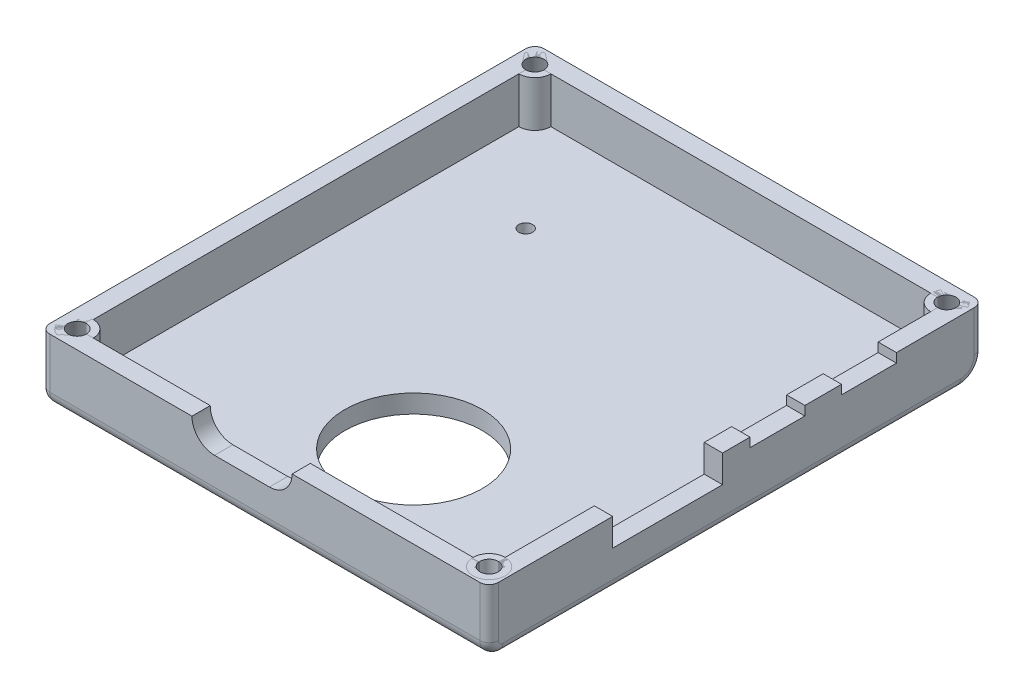
from build123d import *

# Parameters (mm, degrees)
SKETCH1_W             = 49
SKETCH1_H             = 54
BOSS_EXTRUDE1_DEPTH   = 2
SKETCH2_W             = 49
SKETCH2_H             = 54
SKETCH2_W_2           = 45
SKETCH2_H_2           = 50
EXTRUDE_THIN1_DEPTH   = 5
SKETCH3_W             = 12
SKETCH3_H             = 3
CUT_EXTRUDE4_DEPTH    = 2
SKETCH10_W            = 6
SKETCH10_H            = 1
CUT_EXTRUDE5_DEPTH    = 2
SKETCH11_W            = 6
SKETCH11_H            = 1
CUT_EXTRUDE6_DEPTH    = 2
SKETCH16_R            = 7.5
CUT_EXTRUDE7_DEPTH    = 2
CUT_EXTRUDE8_DEPTH    = 2
SKETCH24_R            = 0.75
CUT_EXTRUDE9_DEPTH    = 2
SKETCH26_R            = 1.75
BOSS_EXTRUDE2_DEPTH   = 5
BOSS_EXTRUDE2_2_DEPTH = 5
BOSS_EXTRUDE2_3_DEPTH = 5
BOSS_EXTRUDE2_4_DEPTH = 5
SKETCH27_R            = 1
CUT_EXTRUDE10_DEPTH   = 5
FILLET3_R             = 1.5
FILLET4_R             = 2.5
FILLET5_R             = 1


with BuildPart() as part:
    # Sketch1 → Boss-Extrude1 (new body)
    with BuildSketch(Plane(origin=(0, 0, 0), x_dir=(1, 0, 0), z_dir=(0, 1, 0))):
        Rectangle(SKETCH1_W, SKETCH1_H)
    extrude(amount=BOSS_EXTRUDE1_DEPTH)

    # Sketch2 → Extrude-Thin1 (add)
    with BuildSketch(Plane(origin=(0, 2, 0), x_dir=(1, 0, 0), z_dir=(0, 1, 0))):
        Rectangle(SKETCH2_W, SKETCH2_H)
        Rectangle(SKETCH2_W_2, SKETCH2_H_2, mode=Mode.SUBTRACT)
    extrude(amount=EXTRUDE_THIN1_DEPTH)

    # Sketch3 → Cut-Extrude4 (cut)
    with BuildSketch(Plane(origin=(24.5, 0, 0), x_dir=(0, 0, -1), z_dir=(1, 0, 0))):
        with Locations((-7.5, 5.5)):
            Rectangle(SKETCH3_W, SKETCH3_H)
    extrude(amount=-CUT_EXTRUDE4_DEPTH, mode=Mode.SUBTRACT)

    # Sketch10 → Cut-Extrude5 (cut)
    with BuildSketch(Plane(origin=(24.5, 0, 0), x_dir=(0, 0, -1), z_dir=(1, 0, 0))):
        with Locations((4.5, 6.5)):
            Rectangle(SKETCH10_W, SKETCH10_H)
    extrude(amount=-CUT_EXTRUDE5_DEPTH, mode=Mode.SUBTRACT)

    # Sketch11 → Cut-Extrude6 (cut)
    with BuildSketch(Plane(origin=(24.5, 0, 0), x_dir=(0, 0, -1), z_dir=(1, 0, 0))):
        with Locations((14.5, 6.5)):
            Rectangle(SKETCH11_W, SKETCH11_H)
    extrude(amount=-CUT_EXTRUDE6_DEPTH, mode=Mode.SUBTRACT)

    # Sketch16 → Cut-Extrude7 (cut)
    with BuildSketch(Plane.XZ):
        with Locations((2.25, 13)):
            Circle(SKETCH16_R)
    extrude(amount=-CUT_EXTRUDE7_DEPTH, mode=Mode.SUBTRACT)

    # Sketch22 → Cut-Extrude8 (cut)
    with BuildSketch(Plane.XY.offset(27)):
        with BuildLine():
            Line((0.5, 4.529666561), (-5.5, 4.529666561))
            ThreePointArc((-5.5, 4.529666561), (-7.970333439, 7), (-5.5, 9.470333439))
            Line((-5.5, 9.470333439), (0.5, 9.470333439))
            ThreePointArc((0.5, 9.470333439), (2.970333439, 7), (0.5, 4.529666561))
        make_face()
    extrude(amount=-CUT_EXTRUDE8_DEPTH, mode=Mode.SUBTRACT)

    # Sketch24 → Cut-Extrude9 (cut)
    with BuildSketch(Plane.XZ):
        with Locations((-12.5, -14)):
            Circle(SKETCH24_R)
    extrude(amount=-CUT_EXTRUDE9_DEPTH, mode=Mode.SUBTRACT)


with BuildPart() as body_2:
    # Sketch26 → Boss-Extrude2 (new body)
    with BuildSketch(Plane(origin=(0, 2, 0), x_dir=(1, 0, 0), z_dir=(0, 1, 0))):
        with Locations((-22.5, 25)):
            Circle(SKETCH26_R)
    extrude(amount=BOSS_EXTRUDE2_DEPTH)


with BuildPart() as body_3:
    # Sketch26 → Boss-Extrude2 2 (new body)
    with BuildSketch(Plane(origin=(0, 2, 0), x_dir=(1, 0, 0), z_dir=(0, 1, 0))):
        with Locations((22.5, 25)):
            Circle(SKETCH26_R)
    extrude(amount=BOSS_EXTRUDE2_2_DEPTH)


with BuildPart() as body_4:
    # Sketch26 → Boss-Extrude2 3 (new body)
    with BuildSketch(Plane(origin=(0, 2, 0), x_dir=(1, 0, 0), z_dir=(0, 1, 0))):
        with Locations((22.5, -25)):
            Circle(SKETCH26_R)
    extrude(amount=BOSS_EXTRUDE2_3_DEPTH)


with BuildPart() as body_5:
    # Sketch26 → Boss-Extrude2 4 (new body)
    with BuildSketch(Plane(origin=(0, 2, 0), x_dir=(1, 0, 0), z_dir=(0, 1, 0))):
        with Locations((-22.5, -25)):
            Circle(SKETCH26_R)
    extrude(amount=BOSS_EXTRUDE2_4_DEPTH)


with BuildPart() as cut_extrude10_tool:
    # Sketch27 → Cut-Extrude10 (new body)
    with BuildSketch(Plane(origin=(0, 2, 0), x_dir=(1, 0, 0), z_dir=(0, 1, 0))):
        with Locations((-22.5, 25)):
            Circle(SKETCH27_R)
        with Locations((22.5, 25)):
            Circle(SKETCH27_R)
        with Locations((22.5, -25)):
            Circle(SKETCH27_R)
        with Locations((-22.5, -25)):
            Circle(SKETCH27_R)
    extrude(amount=CUT_EXTRUDE10_DEPTH)


with BuildPart() as part_1:
    add(part.part)

    # Cut-Extrude10: cut by cut_extrude10_tool
    add(cut_extrude10_tool.part, mode=Mode.SUBTRACT)

    # Fillet3
    fillet3_edges = [part_1.edges().sort_by_distance(p)[0] for p in [
        (0, 0, 27),
    ]]
    fillet(fillet3_edges, radius=FILLET3_R)

    # Fillet4
    fillet4_edges = [part_1.edges().sort_by_distance(p)[0] for p in [
        (0, 0, -27),
    ]]
    fillet(fillet4_edges, radius=FILLET4_R)

    # Fillet5
    fillet5_edges = [part_1.edges().sort_by_distance(p)[0] for p in [
        (24.5, 0, 0.5),
        (24.5, 0.439339828, 26.560660172),
        (-24.5, 0.439339828, 26.560660172),
        (-24.5, 0, 0.5),
        (-24.5, 0.732233047, -26.267766953),
        (24.5, 0.732233047, -26.267766953),
        (-24.5, 4.75, -27),
        (24.5, 4.75, -27),
        (24.5, 4.25, 27),
        (-24.5, 4.25, 27),
    ]]
    fillet(fillet5_edges, radius=FILLET5_R)


with BuildPart() as body_2_1:
    add(body_2.part)

    # Cut-Extrude10: cut by cut_extrude10_tool
    add(cut_extrude10_tool.part, mode=Mode.SUBTRACT)


with BuildPart() as body_3_1:
    add(body_3.part)

    # Cut-Extrude10: cut by cut_extrude10_tool
    add(cut_extrude10_tool.part, mode=Mode.SUBTRACT)


with BuildPart() as body_4_1:
    add(body_4.part)

    # Cut-Extrude10: cut by cut_extrude10_tool
    add(cut_extrude10_tool.part, mode=Mode.SUBTRACT)


with BuildPart() as body_5_1:
    add(body_5.part)

    # Cut-Extrude10: cut by cut_extrude10_tool
    add(cut_extrude10_tool.part, mode=Mode.SUBTRACT)


solid = Compound([part_1.part, body_2_1.part, body_3_1.part, body_4_1.part, body_5_1.part])
